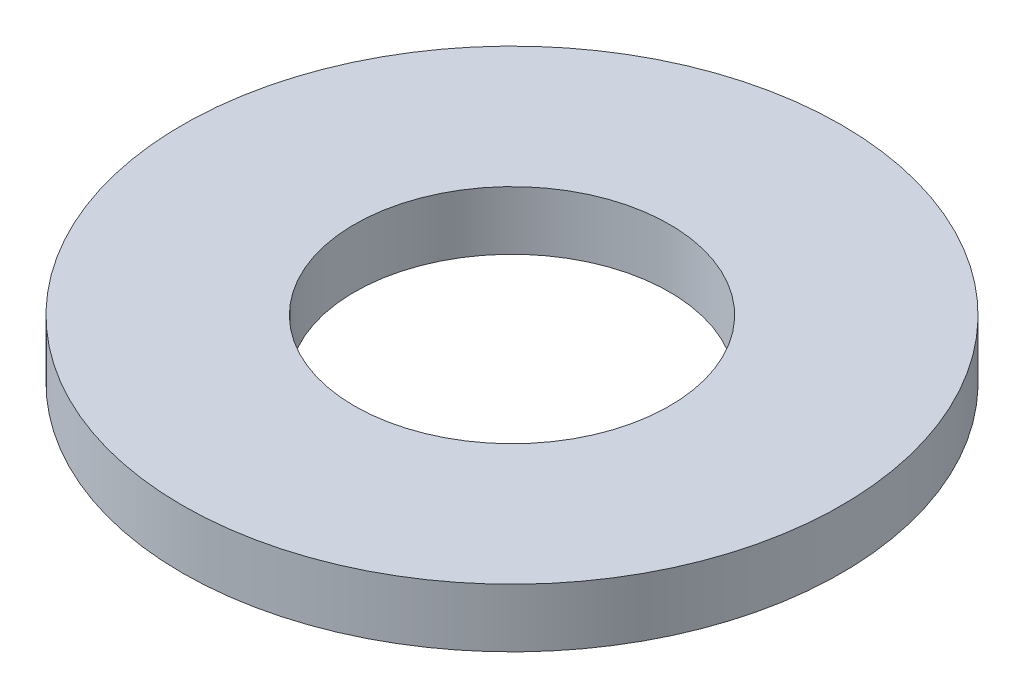
from build123d import *

# Parameters (mm, degrees)
SKETCH1_R      = 4.5
SKETCH1_R_2    = 2.15
EXTRUDE1_DEPTH = 0.8


with BuildPart() as part:
    # Sketch1 → Extrude1 (new body)
    with BuildSketch(Plane(origin=(0, 0, 0), x_dir=(1, 0, 0), z_dir=(0, 1, 0))):
        Circle(SKETCH1_R)
        Circle(SKETCH1_R_2, mode=Mode.SUBTRACT)
    extrude(amount=EXTRUDE1_DEPTH)


solid = part.part
